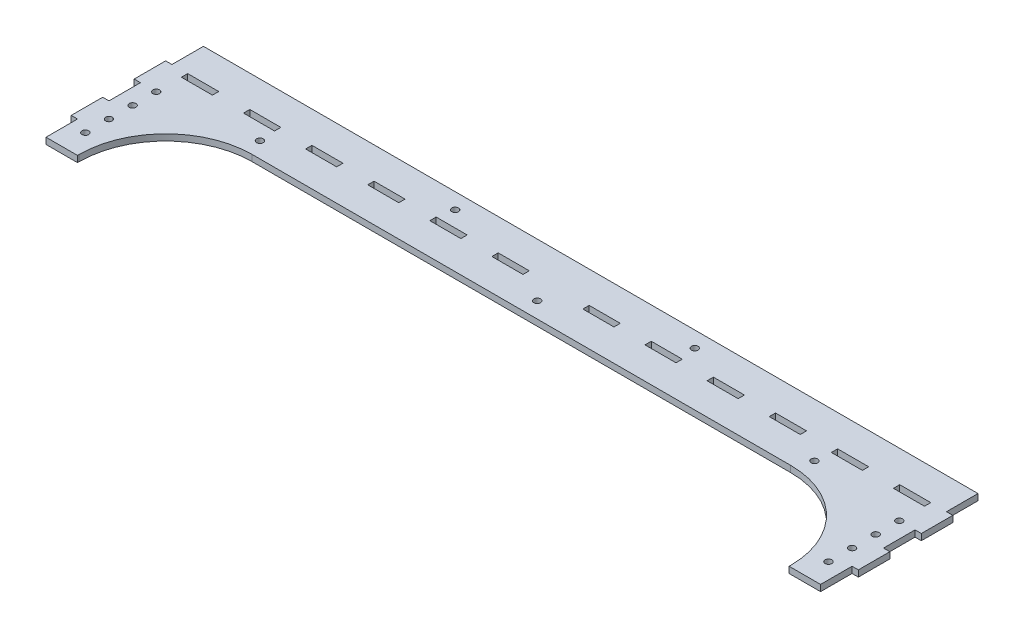
from build123d import *

# Parameters (mm, degrees)
SKETCH1_R           = 2.125
SKETCH1_W           = 19.725
SKETCH1_H           = 4
BOSS_EXTRUDE1_DEPTH = 4


with BuildPart() as part:
    # Sketch1 → Boss-Extrude1 (new body)
    with BuildSketch(Plane(origin=(0, 0, 0), x_dir=(1, 0, 0), z_dir=(0, 1, 0))):
        with BuildLine():
            Line((4, 0), (4, 20))
            Line((4, 20), (0, 20))
            Line((0, 20), (0, 40))
            Line((0, 40), (4, 40))
            Line((4, 40), (4, 60))
            Line((4, 60), (0, 60))
            Line((0, 60), (0, 80))
            Line((0, 80), (4, 80))
            Line((4, 80), (4, 100))
            Line((4, 100), (250, 100))
            Line((250, 100), (496, 100))
            Line((496, 100), (496, 80))
            Line((496, 80), (500, 80))
            Line((500, 80), (500, 60))
            Line((500, 60), (496, 60))
            Line((496, 60), (496, 40))
            Line((496, 40), (500, 40))
            Line((500, 40), (500, 20))
            Line((500, 20), (496, 20))
            Line((496, 20), (496, 0))
            Line((496, 0), (476, 0))
            Line((476, 0), (476, 1))
            ThreePointArc((476, 1), (459.890872965, 39.890872965), (421, 56))
            Line((421, 56), (79, 56))
            ThreePointArc((79, 56), (40.109127035, 39.890872965), (24, 1))
            Line((24, 1), (24, 0))
            Line((24, 0), (4, 0))
        make_face()
        with Locations((14, 15)):
            Circle(SKETCH1_R, mode=Mode.SUBTRACT)
        with Locations((14, 30)):
            Circle(SKETCH1_R, mode=Mode.SUBTRACT)
        with Locations((173.885, 90)):
            Circle(SKETCH1_R, mode=Mode.SUBTRACT)
        with Locations((326.115, 90)):
            Circle(SKETCH1_R, mode=Mode.SUBTRACT)
        with Locations((486, 30)):
            Circle(SKETCH1_R, mode=Mode.SUBTRACT)
        with Locations((486, 15)):
            Circle(SKETCH1_R, mode=Mode.SUBTRACT)
        with Locations((14, 60)):
            Circle(SKETCH1_R, mode=Mode.SUBTRACT)
        with Locations((14, 45)):
            Circle(SKETCH1_R, mode=Mode.SUBTRACT)
        with Locations((486, 45)):
            Circle(SKETCH1_R, mode=Mode.SUBTRACT)
        with Locations((486, 60)):
            Circle(SKETCH1_R, mode=Mode.SUBTRACT)
        with Locations((73.88, 66)):
            Circle(SKETCH1_R, mode=Mode.SUBTRACT)
        with Locations((426.12, 66)):
            Circle(SKETCH1_R, mode=Mode.SUBTRACT)
        with Locations((250, 66)):
            Circle(SKETCH1_R, mode=Mode.SUBTRACT)
        with Locations((63.3125, 78)):
            Rectangle(SKETCH1_W, SKETCH1_H, mode=Mode.SUBTRACT)
        with Locations((23.8625, 78)):
            Rectangle(SKETCH1_W, SKETCH1_H, mode=Mode.SUBTRACT)
        with Locations((102.7625, 78)):
            Rectangle(SKETCH1_W, SKETCH1_H, mode=Mode.SUBTRACT)
        with Locations((142.2125, 78)):
            Rectangle(SKETCH1_W, SKETCH1_H, mode=Mode.SUBTRACT)
        with Locations((181.6625, 78)):
            Rectangle(SKETCH1_W, SKETCH1_H, mode=Mode.SUBTRACT)
        with Locations((221.1125, 78)):
            Rectangle(SKETCH1_W, SKETCH1_H, mode=Mode.SUBTRACT)
        with Locations((278.8875, 78)):
            Rectangle(SKETCH1_W, SKETCH1_H, mode=Mode.SUBTRACT)
        with Locations((318.3375, 78)):
            Rectangle(SKETCH1_W, SKETCH1_H, mode=Mode.SUBTRACT)
        with Locations((357.7875, 78)):
            Rectangle(SKETCH1_W, SKETCH1_H, mode=Mode.SUBTRACT)
        with Locations((397.2375, 78)):
            Rectangle(SKETCH1_W, SKETCH1_H, mode=Mode.SUBTRACT)
        with Locations((436.6875, 78)):
            Rectangle(SKETCH1_W, SKETCH1_H, mode=Mode.SUBTRACT)
        with Locations((476.1375, 78)):
            Rectangle(SKETCH1_W, SKETCH1_H, mode=Mode.SUBTRACT)
    extrude(amount=BOSS_EXTRUDE1_DEPTH)


solid = part.part
